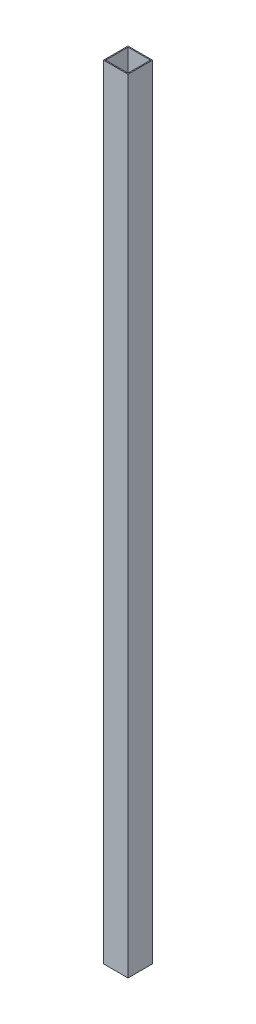
from build123d import *

# Parameters (mm, degrees)
SKETCH1_W           = 76.2
SKETCH1_H           = 76.2
SKETCH1_W_2         = 70.104
SKETCH1_H_2         = 70.104
BOSS_EXTRUDE1_DEPTH = 2438.4


with BuildPart() as part:
    # Sketch1 → Boss-Extrude1 (new body)
    with BuildSketch(Plane(origin=(0, 0, 0), x_dir=(1, 0, 0), z_dir=(0, 1, 0))):
        Rectangle(SKETCH1_W, SKETCH1_H)
        Rectangle(SKETCH1_W_2, SKETCH1_H_2, mode=Mode.SUBTRACT)
    extrude(amount=BOSS_EXTRUDE1_DEPTH)


solid = part.part
